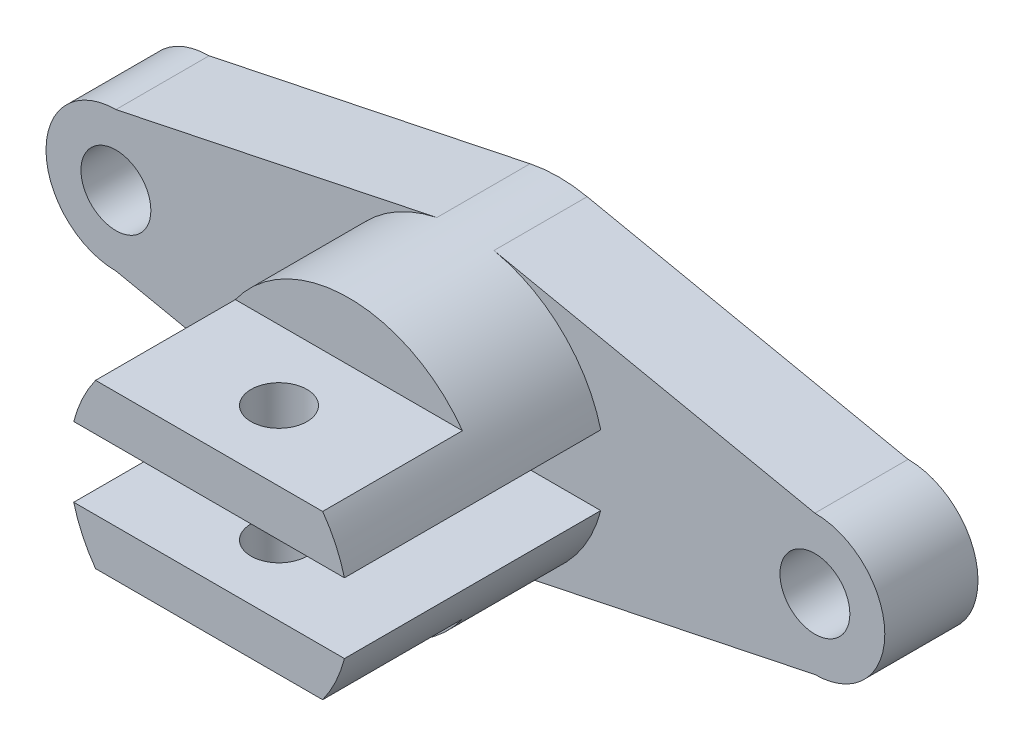
from build123d import *

# Parameters (mm, degrees)
CROQUIS1_R              = 7.5
SALIENTE_EXTRUIR1_DEPTH = 20
SALIENTE_EXTRUIR2_DEPTH = 45
SALIENTE_EXTRUIR3_DEPTH = 75
CROQUIS2_R              = 6
CORTAR_EXTRUIR1_DEPTH   = 75


with BuildPart() as part:
    # Croquis1 → Saliente-Extruir1 (new body)
    with BuildSketch(Plane.XY):
        with BuildLine():
            Line((29.047375097, 7.5), (-29.047375097, 7.5))
            ThreePointArc((-29.047375097, 7.5), (-27.171188586, 12.717173855), (-24.366985862, 17.5))
            ThreePointArc((-24.366985862, 17.5), (-16.360726635, 25.146105543), (-6.126443354, 29.36778323))
            Line((-6.126443354, 29.36778323), (-75, 15))
            ThreePointArc((-75, 15), (-90, 0), (-75, -15))
            Line((-75, -15), (-6.126443354, -29.36778323))
            ThreePointArc((-6.126443354, -29.36778323), (-16.360726635, -25.146105543), (-24.366985862, -17.5))
            ThreePointArc((-24.366985862, -17.5), (-27.171188586, -12.717173855), (-29.047375097, -7.5))
            Line((-29.047375097, -7.5), (29.047375097, -7.5))
            ThreePointArc((29.047375097, -7.5), (27.171188586, -12.717173855), (24.366985862, -17.5))
            ThreePointArc((24.366985862, -17.5), (16.360726635, -25.146105543), (6.126443354, -29.36778323))
            Line((6.126443354, -29.36778323), (75, -15))
            ThreePointArc((75, -15), (90, 0), (75, 15))
            Line((75, 15), (6.126443354, 29.36778323))
            ThreePointArc((6.126443354, 29.36778323), (16.360726635, 25.146105543), (24.366985862, 17.5))
            ThreePointArc((24.366985862, 17.5), (27.171188586, 12.717173855), (29.047375097, 7.5))
        make_face()
        with Locations((-75, 0)):
            Circle(CROQUIS1_R, mode=Mode.SUBTRACT)
        with Locations((75, 0)):
            Circle(CROQUIS1_R, mode=Mode.SUBTRACT)
    extrude(amount=SALIENTE_EXTRUIR1_DEPTH)

    # Croquis1_3 → Saliente-Extruir2 (add)
    with BuildSketch(Plane.XY):
        with BuildLine():
            ThreePointArc((24.366985862, 17.5), (0, 30), (-24.366985862, 17.5))
            Line((-24.366985862, 17.5), (24.366985862, 17.5))
        make_face()
        with BuildLine():
            ThreePointArc((-24.366985862, -17.5), (0, -30), (24.366985862, -17.5))
            Line((24.366985862, -17.5), (-24.366985862, -17.5))
        make_face()
    extrude(amount=SALIENTE_EXTRUIR2_DEPTH)

    # Croquis1_4 → Saliente-Extruir3 (add)
    with BuildSketch(Plane.XY):
        with BuildLine():
            ThreePointArc((-24.366985862, 17.5), (-27.171188586, 12.717173855), (-29.047375097, 7.5))
            Line((-29.047375097, 7.5), (29.047375097, 7.5))
            ThreePointArc((29.047375097, 7.5), (27.171188586, 12.717173855), (24.366985862, 17.5))
            Line((24.366985862, 17.5), (-24.366985862, 17.5))
        make_face()
        with BuildLine():
            ThreePointArc((-29.047375097, -7.5), (-27.171188586, -12.717173855), (-24.366985862, -17.5))
            Line((-24.366985862, -17.5), (24.366985862, -17.5))
            ThreePointArc((24.366985862, -17.5), (27.171188586, -12.717173855), (29.047375097, -7.5))
            Line((29.047375097, -7.5), (-29.047375097, -7.5))
        make_face()
    extrude(amount=SALIENTE_EXTRUIR3_DEPTH)

    # Croquis2 → Cortar-Extruir1 (cut)
    with BuildSketch(Plane.XZ.offset(17.5)):
        with Locations((0, 60)):
            Circle(CROQUIS2_R)
    extrude(amount=-CORTAR_EXTRUIR1_DEPTH, mode=Mode.SUBTRACT)


solid = part.part
